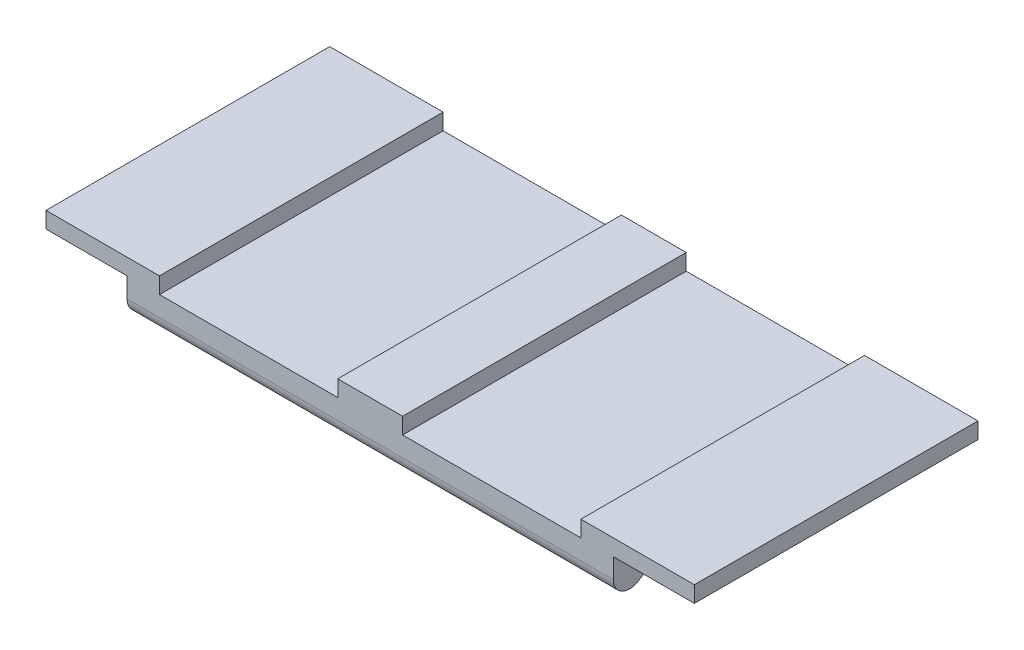
from build123d import *

# Parameters (mm, degrees)
SKETCH1_W               = 60
SKETCH1_H               = 35
BOSS_EXTRUDE1_DEPTH     = 8
CUT_EXTRUDE1_DEPTH      = 1
CUT_EXTRUDE1_DEPTH_BACK = 61
FILLET1_R               = 2
SKETCH3_W               = 22
SKETCH3_H               = 2
CUT_EXTRUDE2_DEPTH      = 36
SKETCH5_W               = 35
SKETCH5_H               = 2
BOSS_EXTRUDE2_DEPTH     = 10


with BuildPart() as part:
    # Sketch1 → Boss-Extrude1 (new body)
    with BuildSketch(Plane(origin=(0, 0, 0), x_dir=(1, 0, 0), z_dir=(0, 1, 0))):
        Rectangle(SKETCH1_W, SKETCH1_H)
    extrude(amount=-BOSS_EXTRUDE1_DEPTH)

    # Sketch2 → Cut-Extrude1 (cut, two sides)
    with BuildSketch(Plane(origin=(30, 0, 0), x_dir=(0, 0, -1), z_dir=(1, 0, 0))) as cut_extrude1_sk:
        Polygon((-12.5, -5), (-17.5, -8), (0, -8), (0, -5), align=None)
        Polygon((0, -5), (0, -8), (17.5, -8), (12.5, -5), align=None)
    extrude(amount=CUT_EXTRUDE1_DEPTH, mode=Mode.SUBTRACT)
    extrude(cut_extrude1_sk.sketch, amount=-CUT_EXTRUDE1_DEPTH_BACK, mode=Mode.SUBTRACT)

    # Fillet1
    fillet1_edges = [part.edges().sort_by_distance(p)[0] for p in [
        (0, -8, -17.5),
        (0, -5, 12.5),
        (0, -5, -12.5),
        (0, -8, 17.5),
    ]]
    fillet(fillet1_edges, radius=FILLET1_R)

    # Sketch3 → Cut-Extrude2 (cut, through all)
    with BuildSketch(Plane.XY.offset(17.5)):
        with Locations((-15, -1)):
            Rectangle(SKETCH3_W, SKETCH3_H)
        with Locations((15, -1)):
            Rectangle(SKETCH3_W, SKETCH3_H)
    extrude(amount=-CUT_EXTRUDE2_DEPTH, mode=Mode.SUBTRACT)

    # Sketch5 → Boss-Extrude2 (add)
    with BuildSketch(Plane.ZY.offset(30)):
        with Locations((0, -1)):
            Rectangle(SKETCH5_W, SKETCH5_H)
    boss_extrude2 = extrude(amount=BOSS_EXTRUDE2_DEPTH)

    # Mirror1: Boss-Extrude2 across plane
    add(boss_extrude2.mirror(Plane(origin=(0, 0, 0), x_dir=(0, 0, 1), z_dir=(1, 0, 0))))


solid = part.part
